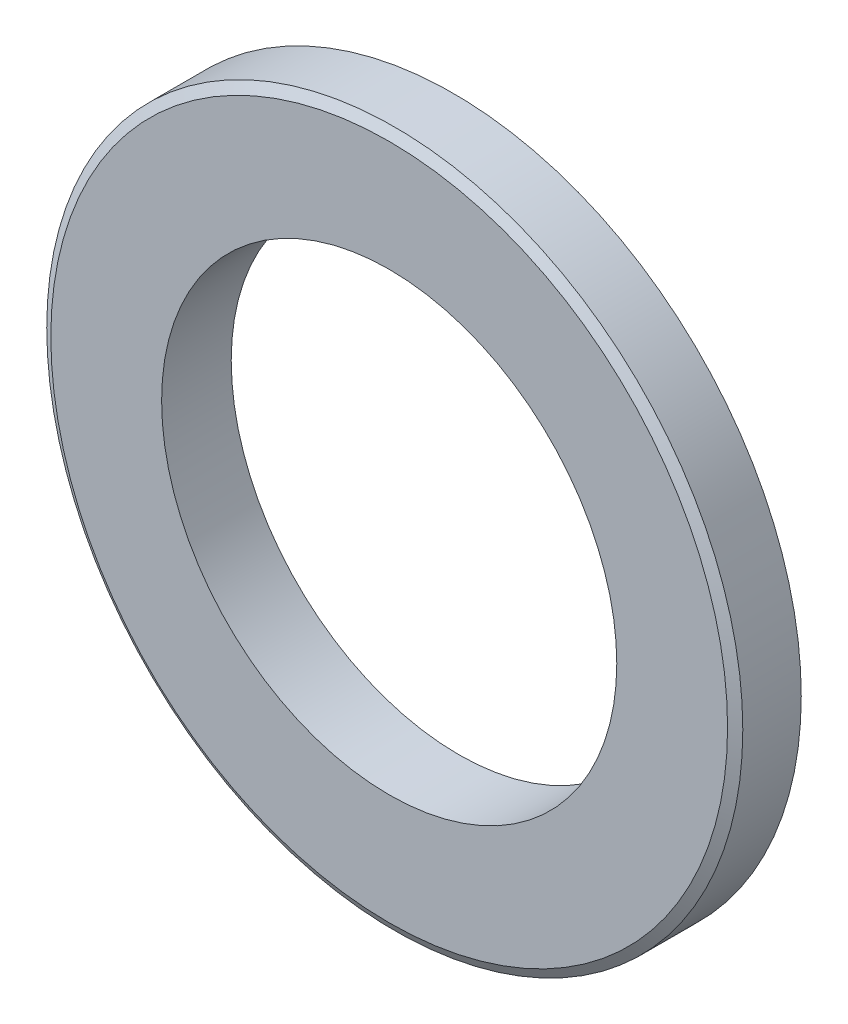
from build123d import *

# Parameters (mm, degrees)
SKETCH3_R                = 15.875
SKETCH3_R_2              = 9.5504
BOSS_EXTRUDE1_DEPTH      = 1.5875
BOSS_EXTRUDE1_DEPTH_BACK = 1.5875
CHAMFER1_SIZE            = 0.254
CHAMFER1_SIZE2           = 0.439940905
CHAMFER1_PART_2_SIZE     = 0.254
CHAMFER1_PART_2_SIZE2    = 0.439940905
CHAMFER2_SIZE            = 0.254
CHAMFER2_SIZE2           = 0.495866606
SKETCH5_R                = 10.380999939
CUT_EXTRUDE1_DEPTH       = 4.1750001


with BuildPart() as part:
    # Sketch3 → Boss-Extrude1 (new body, two sides)
    with BuildSketch(Plane.XY) as boss_extrude1_sk:
        Circle(SKETCH3_R)
        Circle(SKETCH3_R_2, mode=Mode.SUBTRACT)
    extrude(amount=BOSS_EXTRUDE1_DEPTH)
    extrude(boss_extrude1_sk.sketch, amount=-BOSS_EXTRUDE1_DEPTH_BACK)

    # Chamfer1
    chamfer1_edges = [part.edges().sort_by_distance(p)[0] for p in [
        (-15.875, 0, 1.5875),
    ]]
    chamfer1_side = [part.faces().sort_by_distance(p)[0] for p in [
        (-15.875, 0, 0.79375),
    ]]
    chamfer(chamfer1_edges, length=CHAMFER1_SIZE, length2=CHAMFER1_SIZE2, reference=chamfer1_side[0])

    # Chamfer1 part 2
    chamfer1_part_2_edges = [part.edges().sort_by_distance(p)[0] for p in [
        (-15.875, 0, -1.5875),
    ]]
    chamfer1_part_2_side = [part.faces().sort_by_distance(p)[0] for p in [
        (-15.875, 0, -0.79375),
    ]]
    chamfer(chamfer1_part_2_edges, length=CHAMFER1_PART_2_SIZE, length2=CHAMFER1_PART_2_SIZE2, reference=chamfer1_part_2_side[0])

    # Sketch4 → Cut-Revolve1 (revolve, cut)
    with BuildSketch(Plane(origin=(0, 0, 0), x_dir=(0, 0, -1), z_dir=(1, 0, 0))):
        with BuildLine():
            Line((-1.5875, 9.4996), (-1.5875, 9.6012))
            ThreePointArc((-1.5875, 9.6012), (0, 9.5504), (1.5875, 9.6012))
            Line((1.5875, 9.6012), (1.5875, 9.4996))
            Line((1.5875, 9.4996), (-1.5875, 9.4996))
        make_face()
    revolve(axis=Axis((0, 0, 1.5875), (0, 0, -1)), mode=Mode.SUBTRACT)

    # Chamfer2
    chamfer2_edges = [part.edges().sort_by_distance(p)[0] for p in [
        (0, -9.6012, -1.5875),
        (0, -9.6012, 1.5875),
    ]]
    chamfer2_side = [part.faces().sort_by_distance(p)[0] for p in [
        (0, -9.5504, 0),
    ]]
    chamfer(chamfer2_edges, length=CHAMFER2_SIZE, length2=CHAMFER2_SIZE2, reference=chamfer2_side[0])

    # Sketch5 → Cut-Extrude1 (cut, through all)
    with BuildSketch(Plane.XY.offset(1.5875)):
        Circle(SKETCH5_R)
    extrude(amount=-CUT_EXTRUDE1_DEPTH, mode=Mode.SUBTRACT)


solid = part.part
